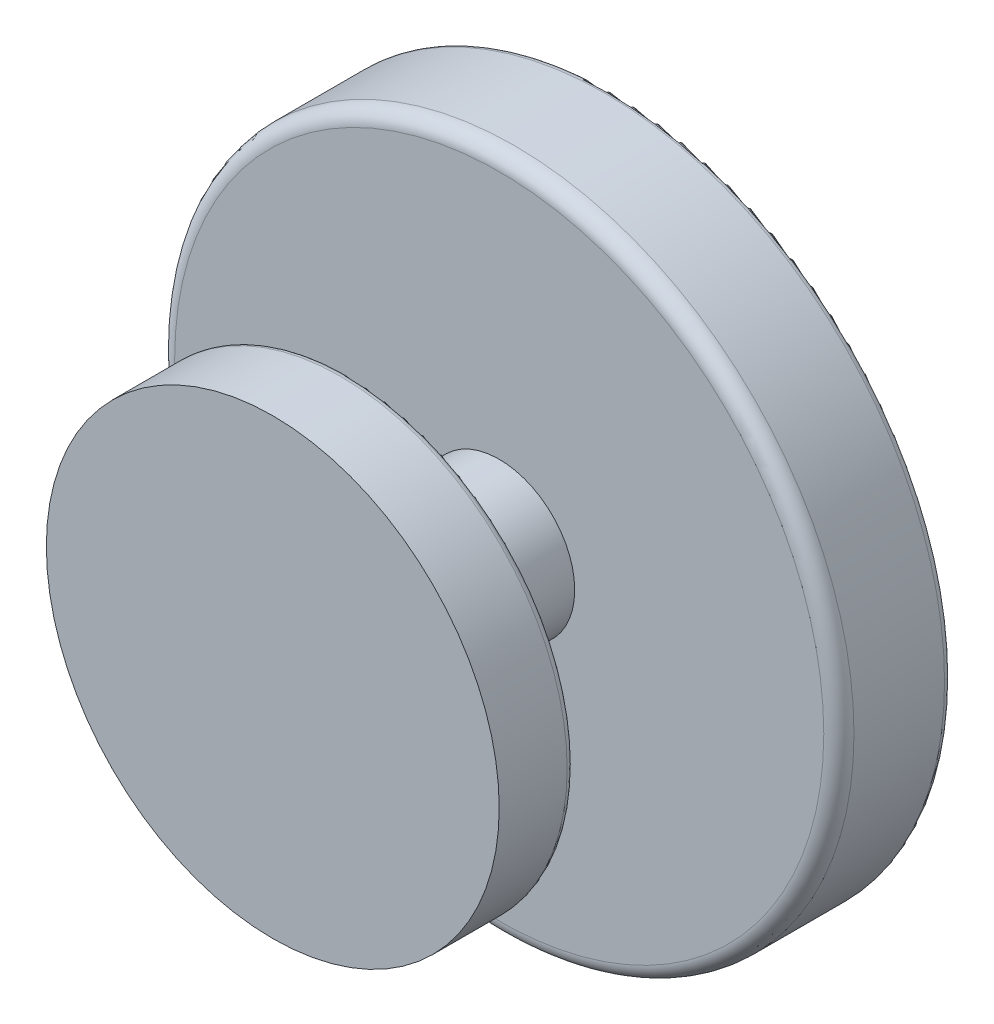
from build123d import *

# Parameters (mm, degrees)
ESQUISSE1_R        = 45
BOSS_EXTRU_1_DEPTH = 15
ESQUISSE3_R        = 10
BOSS_EXTRU_2_DEPTH = 20
ESQUISSE4_R        = 30
BOSS_EXTRU_3_DEPTH = 10
CONG_1_R           = 2
CONG_2_R           = 1
CONG_3_R           = 1


with BuildPart() as part:
    # Esquisse1 → Boss.-Extru.1 (new body)
    with BuildSketch(Plane.XY):
        Circle(ESQUISSE1_R)
    extrude(amount=BOSS_EXTRU_1_DEPTH)

    # Esquisse3 → Boss.-Extru.2 (add)
    with BuildSketch(Plane.XY.offset(15)):
        Circle(ESQUISSE3_R)
    extrude(amount=BOSS_EXTRU_2_DEPTH)

    # Esquisse4 → Boss.-Extru.3 (add)
    with BuildSketch(Plane.XY.offset(35)):
        Circle(ESQUISSE4_R)
    extrude(amount=BOSS_EXTRU_3_DEPTH)

    # Congé1
    cong_1_edges = [part.edges().sort_by_distance(p)[0] for p in [
        (-45, 0, 15),
    ]]
    fillet(cong_1_edges, radius=CONG_1_R)

    # Congé2
    cong_2_edges = [part.edges().sort_by_distance(p)[0] for p in [
        (-30, 0, 35),
    ]]
    fillet(cong_2_edges, radius=CONG_2_R)

    # Congé3
    cong_3_edges = [part.edges().sort_by_distance(p)[0] for p in [
        (-45, 0, 0),
    ]]
    fillet(cong_3_edges, radius=CONG_3_R)


solid = part.part
